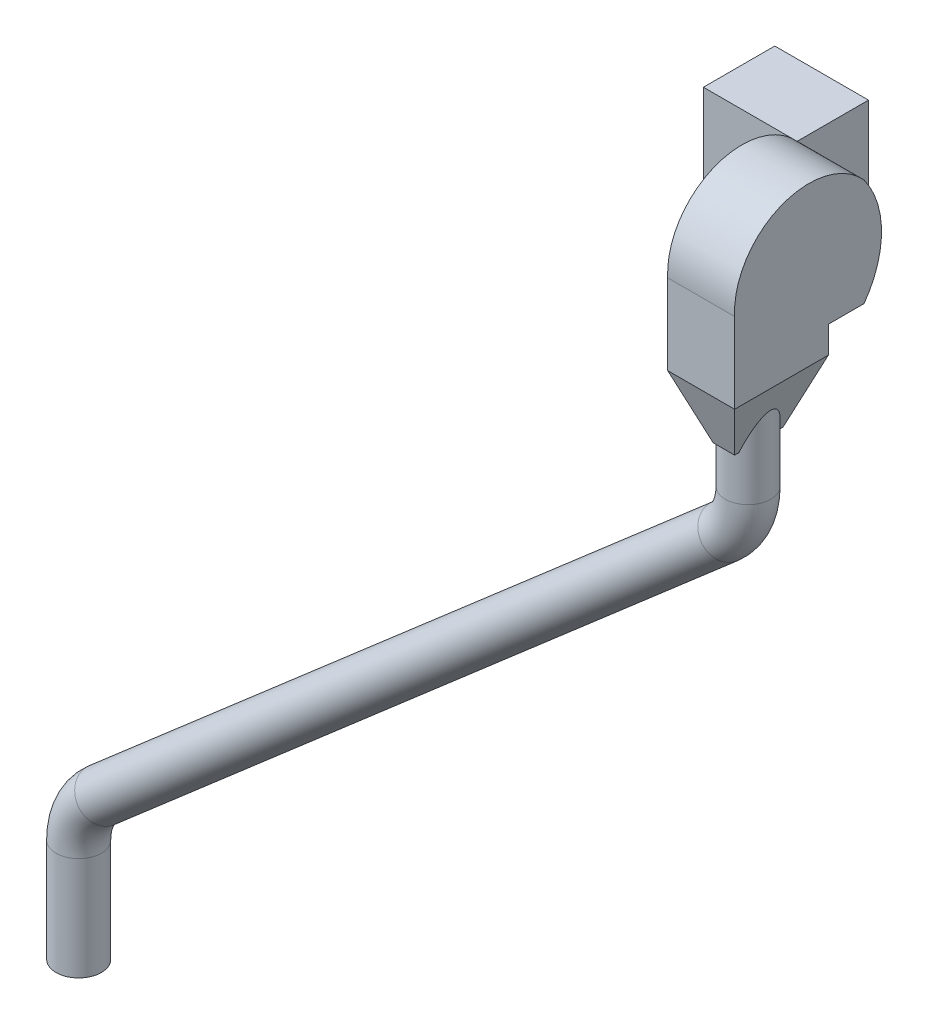
from build123d import *

# Parameters (mm, degrees)
CROQUIS1_W              = 210
CROQUIS1_H              = 240
SALIENTE_EXTRUIR1_DEPTH = 160
SALIENTE_EXTRUIR2_DEPTH = 150
CROQUIS3_W              = 150
CROQUIS3_H              = 210.142141412
SALIENTE_EXTRUIR3_DEPTH = 60
CROQUIS4_R              = 50.8
SALIENTE_EXTRUIR4_DEPTH = 170
CROQUIS5_W              = 150
CROQUIS5_H              = 210.142141412
SALIENTE_EXTRUIR5_DEPTH = 140
SALIENTE_EXTRUIR5_TAPER = 20
CROQUIS6_R              = 50.8
CROQUIS7_R              = 50.8
SALIENTE_EXTRUIR6_DEPTH = 100


with BuildPart() as part:
    # Croquis1 → Saliente-Extruir1 (new body)
    with BuildSketch(Plane.XY):
        Rectangle(CROQUIS1_W, CROQUIS1_H)
    extrude(amount=SALIENTE_EXTRUIR1_DEPTH)


with BuildPart() as body_2:
    # Croquis2 → Saliente-Extruir2 (new body)
    with BuildSketch(Plane(origin=(105, 0, 0), x_dir=(0, 0, -1), z_dir=(1, 0, 0))):
        with BuildLine():
            Line((-160, -120), (-450, -120))
            Line((-450, -120), (-450, 0))
            ThreePointArc((-450, 0), (-347.372372038, 162.399899092), (-160, 120))
            ThreePointArc((-160, 120), (-120.80959106, 0), (-160, -120))
        make_face()
    extrude(amount=SALIENTE_EXTRUIR2_DEPTH)

    # Croquis3 → Saliente-Extruir3 (add)
    with BuildSketch(Plane.XZ.offset(120)):
        with Locations((180, 344.928929294)):
            Rectangle(CROQUIS3_W, CROQUIS3_H)
    extrude(amount=SALIENTE_EXTRUIR3_DEPTH)

    # Croquis4 → Saliente-Extruir4 (add)
    with BuildSketch(Plane.XZ.offset(180)):
        with Locations((180, 344.928929294)):
            Circle(CROQUIS4_R)
    extrude(amount=SALIENTE_EXTRUIR4_DEPTH)

    # Croquis5 → Saliente-Extruir5 (add)
    with BuildSketch(Plane.XZ.offset(180)):
        with Locations((180, 344.928929294)):
            Rectangle(CROQUIS5_W, CROQUIS5_H)
    extrude(amount=SALIENTE_EXTRUIR5_DEPTH, taper=SALIENTE_EXTRUIR5_TAPER)

    # Barrer1: sweep along a curve in space
    with BuildLine() as barrer1_path:
        Line((180, -350, 344.928929294), (180, -419.373633231, 344.928929294))
        ThreePointArc((180, -419.373633231, 344.928929294), (166.447676995, -481.679583531, 344.928929294), (128.239580763, -532.72699565, 344.928929294))
        Line((-1268.239580763, -1743.008935638, 344.928929294), (128.239580763, -532.72699565, 344.928929294))
        ThreePointArc((-1320, -1856.362298057, 344.928929294), (-1306.447676995, -1794.056347757, 344.928929294), (-1268.239580763, -1743.008935638, 344.928929294))
        Line((-1320, -1987.867965644, 344.928929294), (-1320, -1856.362298057, 344.928929294))
    # Croquis6 → Barrer1 (sweep)
    with BuildSketch(Plane.XZ.offset(350)):
        with Locations((180, 344.928929294)):
            Circle(CROQUIS6_R)
    sweep(path=barrer1_path.line)

    # Croquis7 → Saliente-Extruir6 (add)
    with BuildSketch(Plane.XZ.offset(1987.867965644)):
        with Locations((-1320, 344.928929294)):
            Circle(CROQUIS7_R)
    extrude(amount=SALIENTE_EXTRUIR6_DEPTH)


solid = Compound([part.part, body_2.part])
